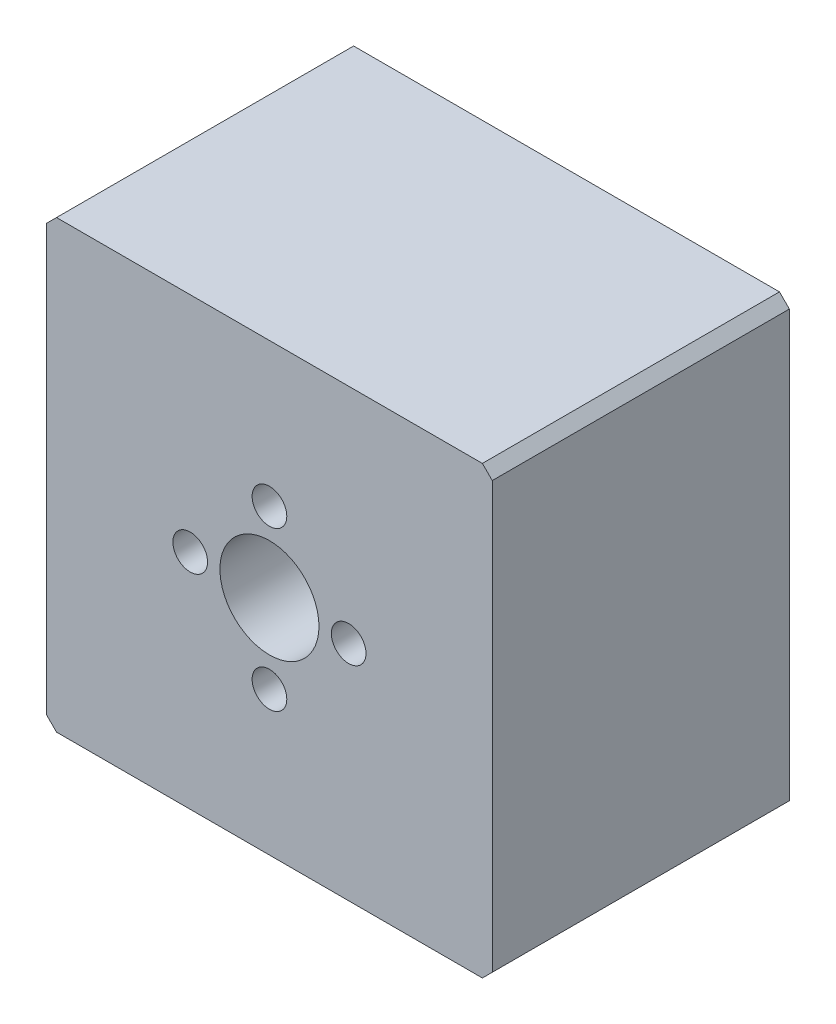
from build123d import *

# Parameters (mm, degrees)
SKETCH1_W           = 45
SKETCH1_H           = 45
SKETCH1_R           = 5
BOSS_EXTRUDE1_DEPTH = 15
SKETCH2_R           = 1.75
CUT_EXTRUDE1_DEPTH  = 10
CHAMFER1_SIZE       = 1
SKETCH3_R           = 2
CUT_EXTRUDE2_DEPTH  = 10


with BuildPart() as part:
    # Sketch1 → Boss-Extrude1 (new body, symmetric)
    with BuildSketch(Plane.XY):
        with Locations((0, -2.5)):
            Rectangle(SKETCH1_W, SKETCH1_H)
        with Locations((0, -2.5)):
            Circle(SKETCH1_R, mode=Mode.SUBTRACT)
    extrude(amount=BOSS_EXTRUDE1_DEPTH, both=True)

    # Sketch2 → Cut-Extrude1 (cut)
    with BuildSketch(Plane.XY.offset(15)):
        with Locations((0, 5.5)):
            Circle(SKETCH2_R)
        with Locations((0, -10.5)):
            Circle(SKETCH2_R)
        with Locations((8, -2.5)):
            Circle(SKETCH2_R)
        with Locations((-8, -2.5)):
            Circle(SKETCH2_R)
    extrude(amount=-CUT_EXTRUDE1_DEPTH, mode=Mode.SUBTRACT)

    # Chamfer1
    chamfer1_edges = [part.edges().sort_by_distance(p)[0] for p in [
        (-22.5, 20, 0),
        (22.5, 20, 0),
        (22.5, -25, 0),
        (-22.5, -25, 0),
    ]]
    chamfer(chamfer1_edges, length=CHAMFER1_SIZE)

    # Sketch3 → Cut-Extrude2 (cut)
    with BuildSketch(Plane.XZ.offset(25)):
        with Locations((-15, 8)):
            Circle(SKETCH3_R)
        with Locations((15, 8)):
            Circle(SKETCH3_R)
        with Locations((15, -8)):
            Circle(SKETCH3_R)
        with Locations((-15, -8)):
            Circle(SKETCH3_R)
    extrude(amount=-CUT_EXTRUDE2_DEPTH, mode=Mode.SUBTRACT)


solid = part.part
